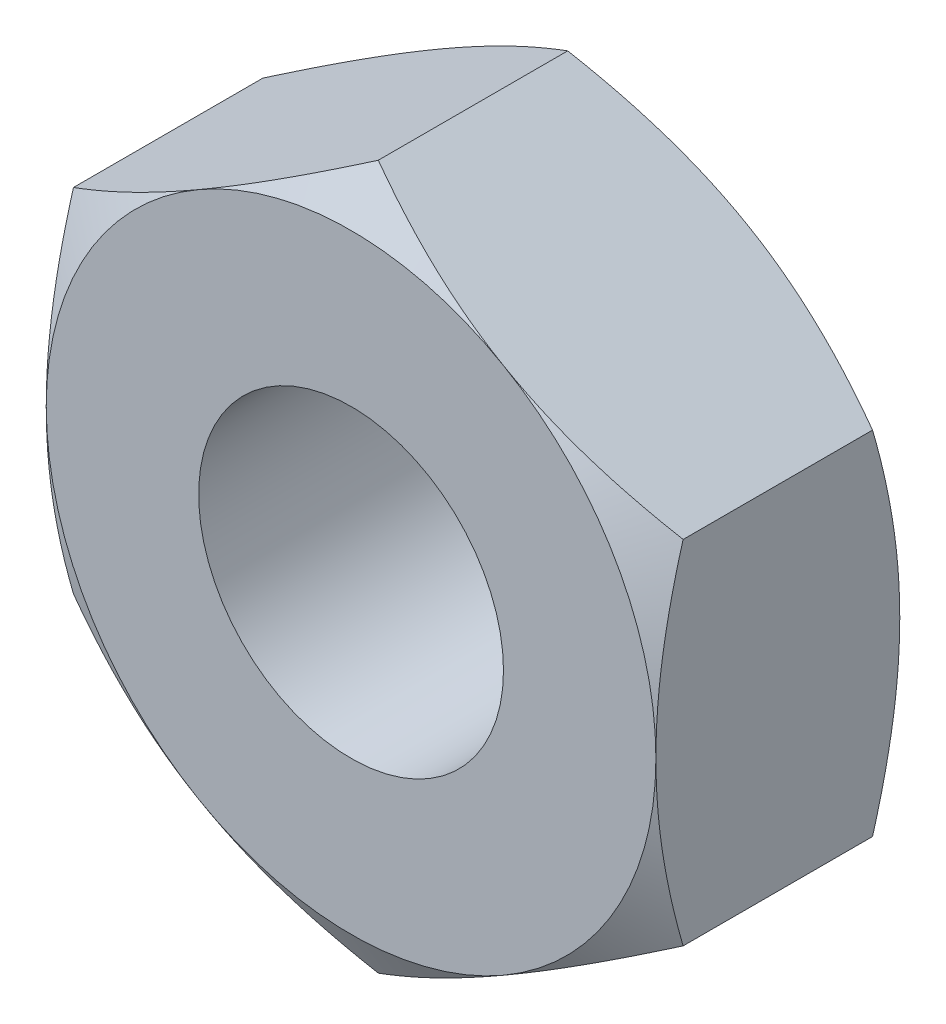
from build123d import *

# Parameters (mm, degrees)
SKETCH2_R                = 1
BOSS_EXTRUDE1_DEPTH      = 0.8
BOSS_EXTRUDE1_DEPTH_BACK = 0.8
SKETCH3_OUTSIDE_W        = 16.27
SKETCH3_OUTSIDE_H        = 16.888
SKETCH3_OUTSIDE_R        = 2
CUT_EXTRUDE1_DEPTH       = 2.6
CUT_EXTRUDE1_TAPER       = 60


with BuildPart() as part:
    # Sketch2 → Boss-Extrude1 (new body, two sides)
    with BuildSketch(Plane.XY) as boss_extrude1_sk:
        Polygon((0, 2.309401077), (-2, 1.154700538), (-2, -1.154700538), (0, -2.309401077), (2, -1.154700538), (2, 1.154700538), align=None)
        Circle(SKETCH2_R, mode=Mode.SUBTRACT)
    extrude(amount=BOSS_EXTRUDE1_DEPTH)
    extrude(boss_extrude1_sk.sketch, amount=-BOSS_EXTRUDE1_DEPTH_BACK)

    # Sketch3 outside → Cut-Extrude1 (cut, through all)
    with BuildSketch(Plane.XY.offset(0.8)):
        Rectangle(SKETCH3_OUTSIDE_W, SKETCH3_OUTSIDE_H)
        Circle(SKETCH3_OUTSIDE_R, mode=Mode.SUBTRACT)
    cut_extrude1 = extrude(amount=-CUT_EXTRUDE1_DEPTH, taper=CUT_EXTRUDE1_TAPER, mode=Mode.SUBTRACT)

    # Mirror1: Cut-Extrude1 across plane
    add(cut_extrude1.mirror(Plane.XY), mode=Mode.SUBTRACT)


solid = part.part
